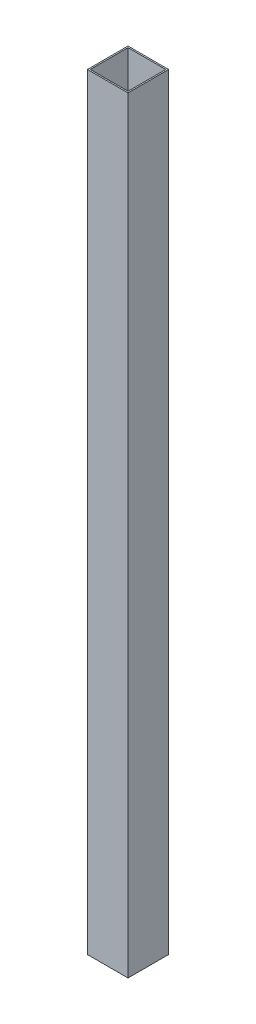
from build123d import *

# Parameters (mm, degrees)
SKETCH1_W           = 25.4
SKETCH1_H           = 25.4
SKETCH1_W_2         = 23.622
SKETCH1_H_2         = 23.622
BOSS_EXTRUDE1_DEPTH = 479.425


with BuildPart() as part:
    # Sketch1 → Boss-Extrude1 (new body)
    with BuildSketch(Plane(origin=(0, 0, 0), x_dir=(1, 0, 0), z_dir=(0, 1, 0))):
        Rectangle(SKETCH1_W, SKETCH1_H)
        Rectangle(SKETCH1_W_2, SKETCH1_H_2, mode=Mode.SUBTRACT)
    extrude(amount=BOSS_EXTRUDE1_DEPTH)


solid = part.part
